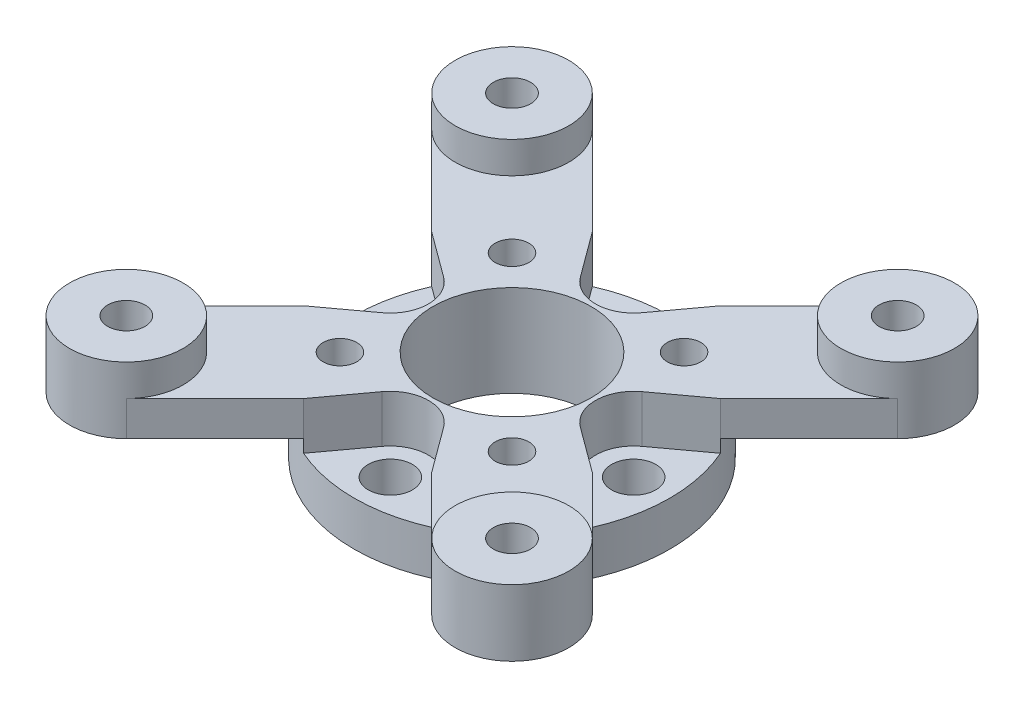
from build123d import *

# Parameters (mm, degrees)
SKETCH1_W                                          = 12.69619
SKETCH1_H                                          = 3.556
BOSS_EXTRUDE1_DEPTH                                = 1.016
BOSS_EXTRUDE2_DEPTH                                = 2.794
SKETCH4_R                                          = 4.56565
BOSS_EXTRUDE3_DEPTH                                = 2.54
SKETCH5_R                                          = 4.56565
BOSS_EXTRUDE4_DEPTH                                = 2.54
SKETCH6_R                                          = 4.56565
BOSS_EXTRUDE5_DEPTH                                = 2.54
SKETCH7_R                                          = 4.56565
BOSS_EXTRUDE6_DEPTH                                = 2.54
HOLE1_D                                            = 12.7254
HOLE1_DEPTH                                        = 7.366
M2_5_CLEARANCE_HOLE1_D                             = 2.7051
M2_5_CLEARANCE_HOLE1_DEPTH                         = 7.366
M3_CLEARANCE_HOLE1_D                               = 3.556
M3_CLEARANCE_HOLE1_DEPTH                           = 3.556
CBORE_FOR_M2_5_HEX_HEAD_MACHINE_SCREW1_D           = 3
CBORE_FOR_M2_5_HEX_HEAD_MACHINE_SCREW1_DEPTH       = 5.334
CBORE_FOR_M2_5_HEX_HEAD_MACHINE_SCREW1_CBORE_D     = 6.35
CBORE_FOR_M2_5_HEX_HEAD_MACHINE_SCREW1_CBORE_DEPTH = 3.048


with BuildPart() as part:
    # Sketch1 → Revolve1 (revolve)
    with BuildSketch(Plane.XY):
        with Locations((6.348095, 1.778)):
            Rectangle(SKETCH1_W, SKETCH1_H)
    revolve(axis=Axis((0, 3.556, 0), (0, -1, 0)))

    # Sketch2 → Boss-Extrude1 (add)
    with BuildSketch(Plane(origin=(0, 3.556, 0), x_dir=(-1, 0, 0), z_dir=(0, 1, 0))):
        with BuildLine():
            Line((2.47008, 7.962716), (5.148593, 11.605397))
            ThreePointArc((5.148593, 11.605397), (8.977562, 8.977562), (11.605397, 5.148593))
            Line((11.605397, 5.148593), (7.962716, 2.47008))
            ThreePointArc((7.962716, 2.47008), (6.713028, 0), (7.962716, -2.47008))
            Line((7.962716, -2.47008), (11.605397, -5.148593))
            ThreePointArc((11.605397, -5.148593), (8.977562, -8.977562), (5.148593, -11.605397))
            Line((5.148593, -11.605397), (2.47008, -7.962716))
            ThreePointArc((2.47008, -7.962716), (0, -6.713028), (-2.47008, -7.962716))
            Line((-2.47008, -7.962716), (-5.148593, -11.605397))
            ThreePointArc((-5.148593, -11.605397), (-8.977562, -8.977562), (-11.605397, -5.148593))
            Line((-11.605397, -5.148593), (-7.962716, -2.47008))
            ThreePointArc((-7.962716, -2.47008), (-6.713028, 0), (-7.962716, 2.47008))
            Line((-7.962716, 2.47008), (-11.605397, 5.148593))
            ThreePointArc((-11.605397, 5.148593), (-8.977562, 8.977562), (-5.148593, 11.605397))
            Line((-5.148593, 11.605397), (-2.47008, 7.962716))
            ThreePointArc((-2.47008, 7.962716), (0, 6.713028), (2.47008, 7.962716))
        make_face()
    extrude(amount=BOSS_EXTRUDE1_DEPTH)

    # Sketch3 → Boss-Extrude2 (add)
    with BuildSketch(Plane(origin=(0, 4.572, 0), x_dir=(-1, 0, 0), z_dir=(0, 1, 0))):
        with BuildLine():
            Line((-7.962716, 2.47008), (-11.605397, 5.148593))
            Line((-11.605397, 5.148593), (-18.728402, 12.271598))
            ThreePointArc((-18.728402, 12.271598), (-18.728402, 18.728402), (-12.271598, 18.728402))
            Line((-12.271598, 18.728402), (-5.148593, 11.605397))
            Line((-5.148593, 11.605397), (-2.47008, 7.962716))
            ThreePointArc((-2.47008, 7.962716), (0, 6.713028), (2.47008, 7.962716))
            Line((2.47008, 7.962716), (5.148593, 11.605397))
            Line((5.148593, 11.605397), (12.271598, 18.728402))
            ThreePointArc((12.271598, 18.728402), (18.728402, 18.728402), (18.728402, 12.271598))
            Line((18.728402, 12.271598), (11.605397, 5.148593))
            Line((11.605397, 5.148593), (7.962716, 2.47008))
            ThreePointArc((7.962716, 2.47008), (6.713028, 0), (7.962716, -2.47008))
            Line((7.962716, -2.47008), (11.605397, -5.148593))
            Line((11.605397, -5.148593), (18.728402, -12.271598))
            ThreePointArc((18.728402, -12.271598), (18.728402, -18.728402), (12.271598, -18.728402))
            Line((12.271598, -18.728402), (5.148593, -11.605397))
            Line((5.148593, -11.605397), (2.47008, -7.962716))
            ThreePointArc((2.47008, -7.962716), (0, -6.713028), (-2.47008, -7.962716))
            Line((-2.47008, -7.962716), (-5.148593, -11.605397))
            Line((-5.148593, -11.605397), (-12.271598, -18.728402))
            ThreePointArc((-12.271598, -18.728402), (-18.728402, -18.728402), (-18.728402, -12.271598))
            Line((-18.728402, -12.271598), (-11.605397, -5.148593))
            Line((-11.605397, -5.148593), (-7.962716, -2.47008))
            ThreePointArc((-7.962716, -2.47008), (-6.713028, 0), (-7.962716, 2.47008))
        make_face()
    extrude(amount=BOSS_EXTRUDE2_DEPTH)

    # Sketch4 → Boss-Extrude3 (add)
    with BuildSketch(Plane(origin=(0, 7.366, 0), x_dir=(-1, 0, 0), z_dir=(0, 1, 0))):
        with Locations((-15.5, -15.5)):
            Circle(SKETCH4_R)
    extrude(amount=BOSS_EXTRUDE3_DEPTH)

    # Sketch5 → Boss-Extrude4 (add)
    with BuildSketch(Plane(origin=(0, 7.366, 0), x_dir=(-1, 0, 0), z_dir=(0, 1, 0))):
        with Locations((15.5, -15.5)):
            Circle(SKETCH5_R)
    extrude(amount=BOSS_EXTRUDE4_DEPTH)

    # Sketch6 → Boss-Extrude5 (add)
    with BuildSketch(Plane(origin=(0, 7.366, 0), x_dir=(-1, 0, 0), z_dir=(0, 1, 0))):
        with Locations((15.5, 15.5)):
            Circle(SKETCH6_R)
    extrude(amount=BOSS_EXTRUDE5_DEPTH)

    # Sketch7 → Boss-Extrude6 (add)
    with BuildSketch(Plane(origin=(0, 7.366, 0), x_dir=(-1, 0, 0), z_dir=(0, 1, 0))):
        with Locations((-15.5, 15.5)):
            Circle(SKETCH7_R)
    extrude(amount=BOSS_EXTRUDE6_DEPTH)

    # Hole1
    with Locations(Plane(origin=(0, 7.366, 0), x_dir=(1, 0, 0), z_dir=(0, 1, 0))):
        with Locations((0, 0)):
            Hole(HOLE1_D / 2, depth=HOLE1_DEPTH)

    # M2.5 Clearance Hole1
    with Locations(Plane(origin=(0, 7.366, 0), x_dir=(1, 0, 0), z_dir=(0, 1, 0))):
        with Locations((6.914797, -6.914797), (-6.914797, 6.914797), (6.914797, 6.914797), (-6.914797, -6.914797)):
            Hole(M2_5_CLEARANCE_HOLE1_D / 2, depth=M2_5_CLEARANCE_HOLE1_DEPTH)

    # M3 Clearance Hole1
    with Locations(Plane(origin=(0, 3.556, 0), x_dir=(1, 0, 0), z_dir=(0, 1, 0))):
        with Locations((0, -9.779), (-9.779, 0), (0, 9.779), (9.779, 0)):
            Hole(M3_CLEARANCE_HOLE1_D / 2, depth=M3_CLEARANCE_HOLE1_DEPTH)

    # CBORE for M2.5 Hex Head Machine Screw1
    with Locations(Plane(origin=(0, 4.572, 0), x_dir=(-1, 0, 0), z_dir=(0, -1, 0))):
        with Locations((-15.5, 15.5), (15.5, 15.5), (15.5, -15.5), (-15.5, -15.5)):
            CounterBoreHole(CBORE_FOR_M2_5_HEX_HEAD_MACHINE_SCREW1_D / 2, CBORE_FOR_M2_5_HEX_HEAD_MACHINE_SCREW1_CBORE_D / 2, CBORE_FOR_M2_5_HEX_HEAD_MACHINE_SCREW1_CBORE_DEPTH, depth=CBORE_FOR_M2_5_HEX_HEAD_MACHINE_SCREW1_DEPTH)


solid = part.part
